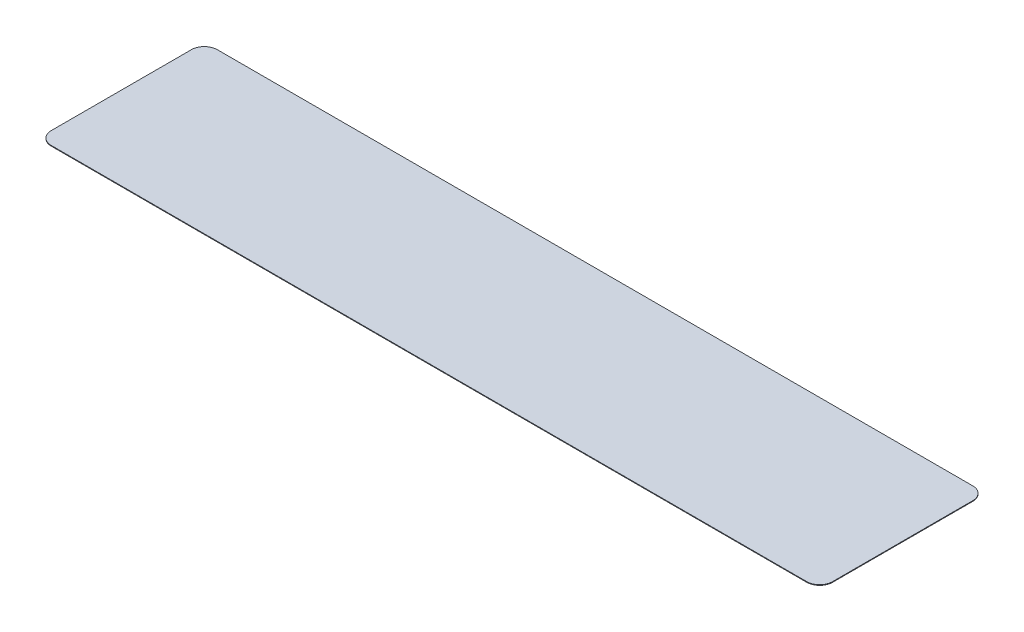
from build123d import *

# Parameters (mm, degrees)
EXTRUDE2_DEPTH = 0.0762


with BuildPart() as part:
    # Sketch1 → Extrude2 (new body)
    with BuildSketch(Plane(origin=(0, 0, 0), x_dir=(1, 0, 0), z_dir=(0, 1, 0))):
        with BuildLine():
            Line((-44.5135, 9.779), (44.5135, 9.779))
            ThreePointArc((44.5135, 9.779), (45.591130735, 9.332630735), (46.0375, 8.255))
            Line((46.0375, 8.255), (46.0375, -8.255))
            ThreePointArc((46.0375, -8.255), (45.591130735, -9.332630735), (44.5135, -9.779))
            Line((44.5135, -9.779), (-44.5135, -9.779))
            ThreePointArc((-44.5135, -9.779), (-45.591130735, -9.332630735), (-46.0375, -8.255))
            Line((-46.0375, -8.255), (-46.0375, 8.255))
            ThreePointArc((-46.0375, 8.255), (-45.591130735, 9.332630735), (-44.5135, 9.779))
        make_face()
    extrude(amount=EXTRUDE2_DEPTH)


solid = part.part
